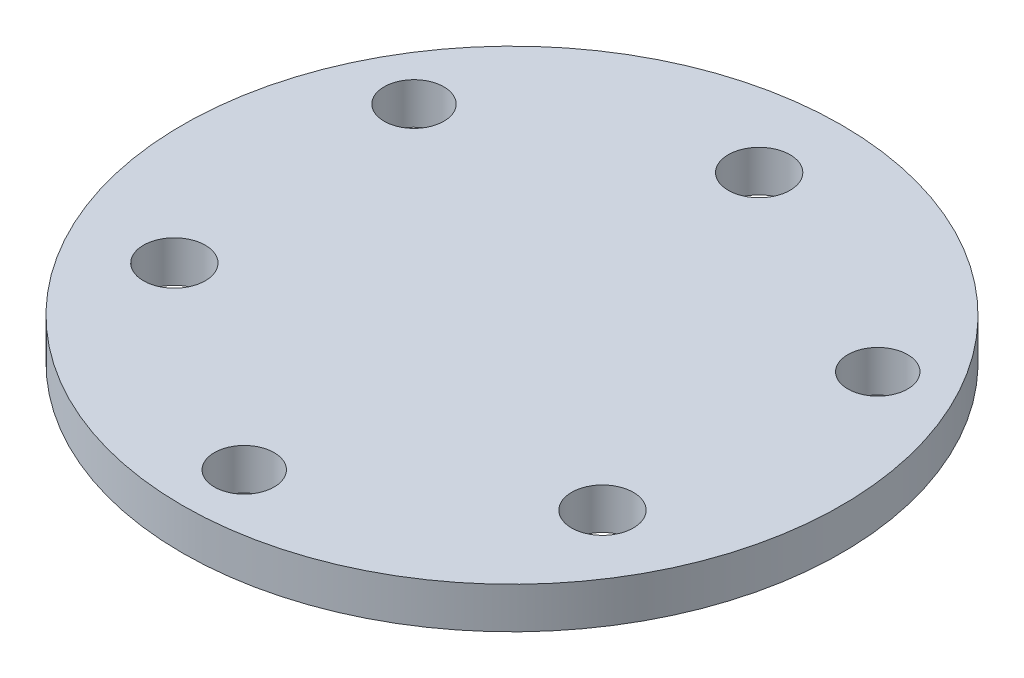
from build123d import *

# Parameters (mm, degrees)
SKETCH_1_R      = 16
SKETCH_1_R_2    = 1.5
SKETCH_1_R_3    = 1.45
EXTRUDE_1_DEPTH = 2


with BuildPart() as part:
    # 草图1 → 凸台-拉伸1 (new body)
    with BuildSketch(Plane(origin=(0, 0, 0), x_dir=(1, 0, 0), z_dir=(0, 1, 0))):
        Circle(SKETCH_1_R)
        with Locations((-10.392304845, -6)):
            Circle(SKETCH_1_R_2, mode=Mode.SUBTRACT)
        with Locations((0, 12)):
            Circle(SKETCH_1_R_2, mode=Mode.SUBTRACT)
        with Locations((10.392304845, -6)):
            Circle(SKETCH_1_R_2, mode=Mode.SUBTRACT)
        with Locations((-11.258330249, 6.5)):
            Circle(SKETCH_1_R_3, mode=Mode.SUBTRACT)
        with Locations((0, -13)):
            Circle(SKETCH_1_R_3, mode=Mode.SUBTRACT)
        with Locations((11.258330249, 6.5)):
            Circle(SKETCH_1_R_3, mode=Mode.SUBTRACT)
    extrude(amount=EXTRUDE_1_DEPTH)


solid = part.part
